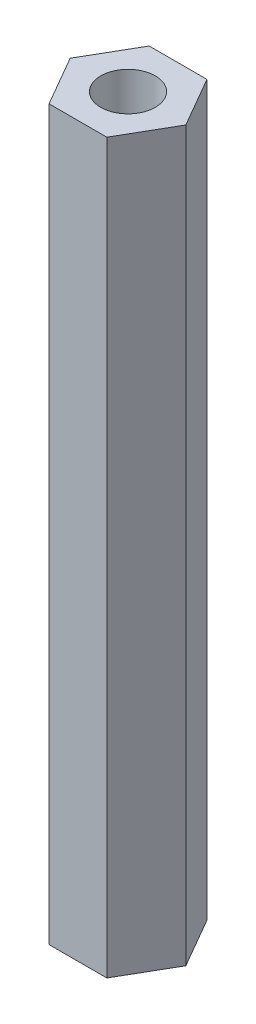
from build123d import *

# Parameters (mm, degrees)
BOSS_EXTRUDE1_DEPTH = 40
SKETCH2_R           = 1.5
CUT_EXTRUDE1_DEPTH  = 10


with BuildPart() as part:
    # Sketch1 → Boss-Extrude1 (new body)
    with BuildSketch(Plane(origin=(0, 0, 0), x_dir=(1, 0, 0), z_dir=(0, 1, 0))):
        Polygon((3.175426481, 0), (1.58771324, 2.75), (-1.58771324, 2.75), (-3.175426481, 0), (-1.58771324, -2.75), (1.58771324, -2.75), align=None)
    extrude(amount=BOSS_EXTRUDE1_DEPTH)

    # Sketch2 → Cut-Extrude1 (cut)
    with BuildSketch(Plane(origin=(0, 40, 0), x_dir=(1, 0, 0), z_dir=(0, 1, 0))):
        Circle(SKETCH2_R)
    cut_extrude1 = extrude(amount=-CUT_EXTRUDE1_DEPTH, mode=Mode.SUBTRACT)

    # Mirror1: Cut-Extrude1 across plane
    add(cut_extrude1.mirror(Plane(origin=(0, 20, 0), x_dir=(0, 0, 1), z_dir=(0, -1, 0))), mode=Mode.SUBTRACT)


solid = part.part
